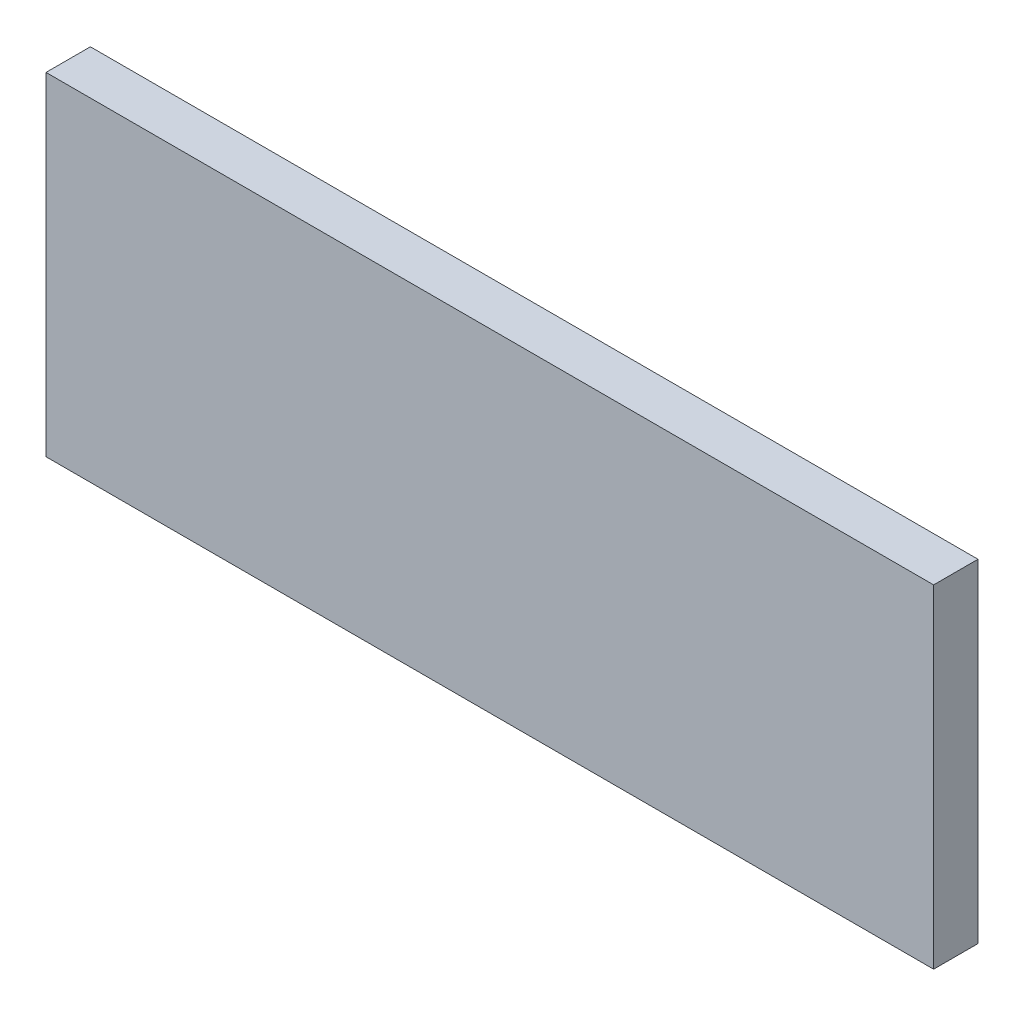
from build123d import *

# Parameters (mm, degrees)
SKETCH1_W           = 80
SKETCH1_H           = 30
BOSS_EXTRUDE1_DEPTH = 4


with BuildPart() as part:
    # Sketch1 → Boss-Extrude1 (new body)
    with BuildSketch(Plane.XY):
        Rectangle(SKETCH1_W, SKETCH1_H)
    extrude(amount=BOSS_EXTRUDE1_DEPTH)


solid = part.part
